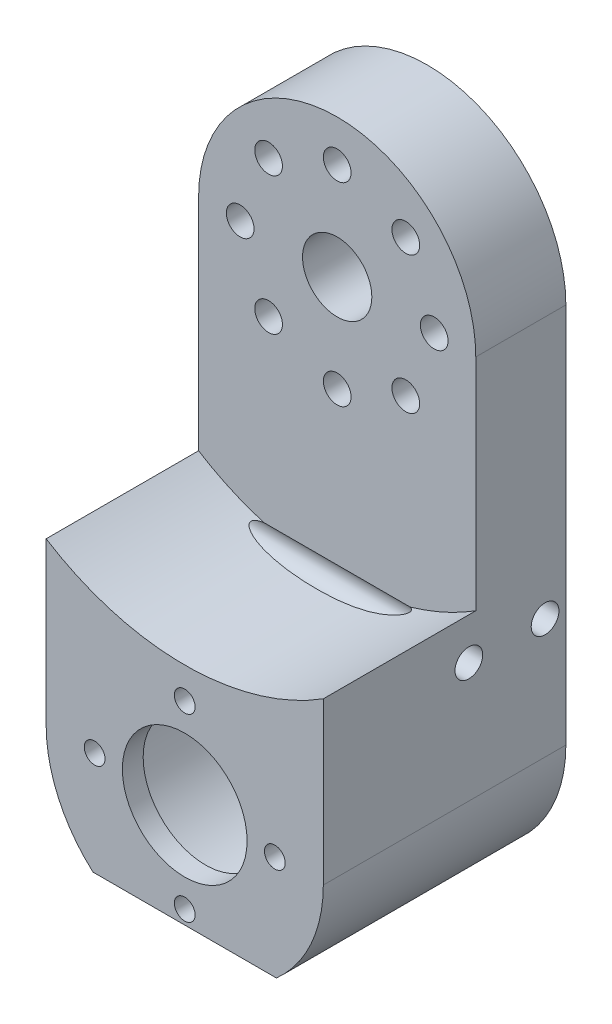
from build123d import *

# Parameters (mm, degrees)
ESQUISSE1_R           = 15
ESQUISSE1_R_2         = 5
ESQUISSE1_R_3         = 2
EXTRUSION1_DEPTH      = 13
ESQUISSE2_R           = 9
ESQUISSE2_R_2         = 1.5
EXTRUSION2_DEPTH      = 22
ESQUISSE3_R           = 15
EXTRUSION3_DEPTH      = 19
EXTRUSION4_DEPTH      = 21
EXTRUSION4_DEPTH_BACK = 21
EXTRUSION5_REACH      = 42
ESQUISSE5_R           = 2


with BuildPart() as part:
    # Esquisse1 → Extrusion1 (new body)
    with BuildSketch(Plane.XY):
        with BuildLine():
            Line((20, -20), (20, -75))
            ThreePointArc((20, -75), (0, -95), (-20, -75))
            Line((-20, -75), (-20, -20))
            ThreePointArc((-20, -20), (0, 0), (20, -20))
        make_face()
        with Locations((0, -75)):
            Circle(ESQUISSE1_R, mode=Mode.SUBTRACT)
        with Locations((0, -20)):
            Circle(ESQUISSE1_R_2, mode=Mode.SUBTRACT)
        with Locations((-14, -20)):
            Circle(ESQUISSE1_R_3, mode=Mode.SUBTRACT)
        with Locations((-9.899494937, -10.100505063)):
            Circle(ESQUISSE1_R_3, mode=Mode.SUBTRACT)
        with Locations((0, -6)):
            Circle(ESQUISSE1_R_3, mode=Mode.SUBTRACT)
        with Locations((9.899494937, -10.100505063)):
            Circle(ESQUISSE1_R_3, mode=Mode.SUBTRACT)
        with Locations((14, -20)):
            Circle(ESQUISSE1_R_3, mode=Mode.SUBTRACT)
        with Locations((9.899494937, -29.899494937)):
            Circle(ESQUISSE1_R_3, mode=Mode.SUBTRACT)
        with Locations((0, -34)):
            Circle(ESQUISSE1_R_3, mode=Mode.SUBTRACT)
        with Locations((-9.899494937, -29.899494937)):
            Circle(ESQUISSE1_R_3, mode=Mode.SUBTRACT)
    extrude(amount=EXTRUSION1_DEPTH)

    # Esquisse2 → Extrusion2 (add)
    with BuildSketch(Plane.XY.offset(13)):
        with BuildLine():
            Line((-20, -75), (-20, -51.721443851))
            ThreePointArc((-20, -51.721443851), (0, -57.5), (20, -51.721443851))
            Line((20, -51.721443851), (20, -75))
            ThreePointArc((20, -75), (0, -95), (-20, -75))
        make_face()
        with Locations((0, -75)):
            Circle(ESQUISSE2_R, mode=Mode.SUBTRACT)
        with Locations((0, -62)):
            Circle(ESQUISSE2_R_2, mode=Mode.SUBTRACT)
        with Locations((0, -88)):
            Circle(ESQUISSE2_R_2, mode=Mode.SUBTRACT)
        with Locations((-13, -75)):
            Circle(ESQUISSE2_R_2, mode=Mode.SUBTRACT)
        with Locations((13, -75)):
            Circle(ESQUISSE2_R_2, mode=Mode.SUBTRACT)
    extrude(amount=EXTRUSION2_DEPTH)

    # Esquisse3 → Extrusion3 (cut)
    with BuildSketch(Plane(origin=(0, 0, 13), x_dir=(-1, 0, 0), z_dir=(0, 0, -1))):
        with Locations((0, -75)):
            Circle(ESQUISSE3_R)
    extrude(amount=-EXTRUSION3_DEPTH, mode=Mode.SUBTRACT)

    # Esquisse4 → Extrusion4 (cut, two sides)
    with BuildSketch(Plane(origin=(0, 0, 0), x_dir=(0, 0, -1), z_dir=(1, 0, 0))) as extrusion4_sk:
        Polygon((-35, -95), (-30, -95), (-35, -90), align=None)
    extrude(amount=EXTRUSION4_DEPTH, mode=Mode.SUBTRACT)
    extrude(extrusion4_sk.sketch, amount=-EXTRUSION4_DEPTH_BACK, mode=Mode.SUBTRACT)

    # Esquisse5 → Extrusion5 (cut, up to next)
    with BuildSketch(Plane.ZY.offset(20), mode=Mode.PRIVATE) as extrusion5_sk1:
        with Locations((14, -57.721443851)):
            Circle(ESQUISSE5_R)
    extrusion5_tool1 = extrude(extrusion5_sk1.sketch, amount=-EXTRUSION5_REACH, mode=Mode.PRIVATE) & part.part
    add(extrusion5_tool1.solids().sort_by_distance((-20, -57.721444, 14))[0], mode=Mode.SUBTRACT)
    # Esquisse5 → Extrusion5 (cut, up to next)
    with BuildSketch(Plane.ZY.offset(20), mode=Mode.PRIVATE) as extrusion5_sk2:
        with Locations((3, -57.721443851)):
            Circle(ESQUISSE5_R)
    extrusion5_tool2 = extrude(extrusion5_sk2.sketch, amount=-EXTRUSION5_REACH, mode=Mode.PRIVATE) & part.part
    add(extrusion5_tool2.solids().sort_by_distance((-20, -57.721444, 3))[0], mode=Mode.SUBTRACT)


solid = part.part
